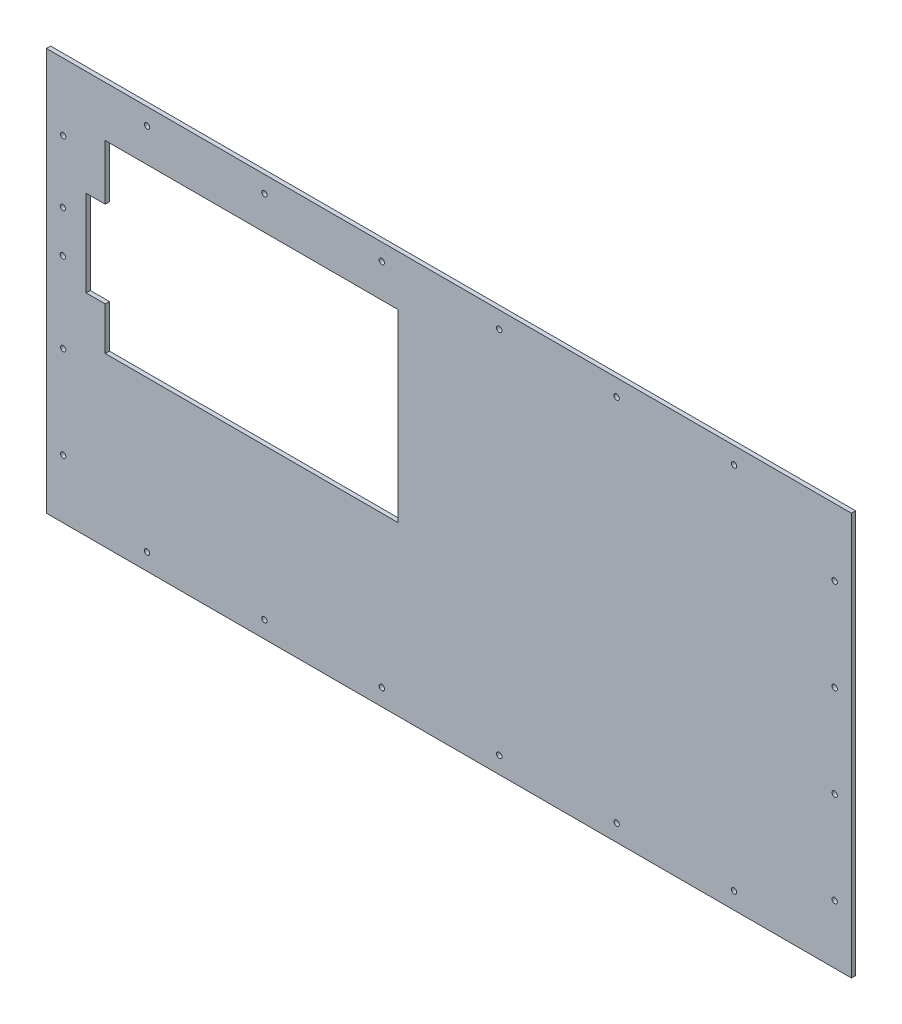
from build123d import *

# Parameters (mm, degrees)
SKETCH1_W               = 609.6
SKETCH1_H               = 304.8
BOSS_EXTRUDE1_DEPTH     = 3.175
SKETCH5_R               = 2.032
CUT_EXTRUDE4_DEPTH      = 4.175
SKETCH6_R               = 2.032
CUT_EXTRUDE5_DEPTH      = 10
CUT_EXTRUDE5_DEPTH_BACK = 3.175
SKETCH20_R              = 2.032
CUT_EXTRUDE17_DEPTH     = 4.175
SKETCH8_W               = 221.700000084
SKETCH8_H               = 139.7
CUT_EXTRUDE6_DEPTH      = 3.175
SKETCH19_W              = 14.489703264
SKETCH19_H              = 65.374013416
CUT_EXTRUDE16_DEPTH     = 4.175


with BuildPart() as part:
    # Sketch1 → Boss-Extrude1 (new body)
    with BuildSketch(Plane.XY):
        with Locations((-304.8, 152.4)):
            Rectangle(SKETCH1_W, SKETCH1_H)
    extrude(amount=BOSS_EXTRUDE1_DEPTH)

    # Sketch5 → Cut-Extrude4 (cut, through all)
    with BuildSketch(Plane.XY.offset(3.175)):
        with Locations((-533.4, 12.7)):
            Circle(SKETCH5_R)
        with Locations((-444.5, 12.7)):
            Circle(SKETCH5_R)
        with Locations((-355.6, 12.7)):
            Circle(SKETCH5_R)
        with Locations((-266.7, 12.7)):
            Circle(SKETCH5_R)
        with Locations((-177.8, 12.7)):
            Circle(SKETCH5_R)
        with Locations((-88.9, 12.7)):
            Circle(SKETCH5_R)
        with Locations((-88.9, 292.1)):
            Circle(SKETCH5_R)
        with Locations((-177.8, 292.1)):
            Circle(SKETCH5_R)
        with Locations((-266.7, 292.1)):
            Circle(SKETCH5_R)
        with Locations((-355.6, 292.1)):
            Circle(SKETCH5_R)
        with Locations((-444.5, 292.1)):
            Circle(SKETCH5_R)
        with Locations((-533.4, 292.1)):
            Circle(SKETCH5_R)
    extrude(amount=-CUT_EXTRUDE4_DEPTH, mode=Mode.SUBTRACT)

    # Sketch6 → Cut-Extrude5 (cut, two sides)
    with BuildSketch(Plane.XY.offset(3.175)) as cut_extrude5_sk:
        with Locations((-596.9, 254)):
            Circle(SKETCH6_R)
        with Locations((-596.9, 114.3)):
            Circle(SKETCH6_R)
        with Locations((-596.9, 44.45)):
            Circle(SKETCH6_R)
        with Locations((-12.7, 254)):
            Circle(SKETCH6_R)
        with Locations((-12.7, 184.15)):
            Circle(SKETCH6_R)
        with Locations((-12.7, 114.3)):
            Circle(SKETCH6_R)
        with Locations((-12.7, 44.45)):
            Circle(SKETCH6_R)
    extrude(amount=CUT_EXTRUDE5_DEPTH, mode=Mode.SUBTRACT)
    extrude(cut_extrude5_sk.sketch, amount=-CUT_EXTRUDE5_DEPTH_BACK, mode=Mode.SUBTRACT)

    # Sketch20 → Cut-Extrude17 (cut, through all)
    with BuildSketch(Plane.XY.offset(3.175)):
        with Locations((-597.110646497, 175.018670592)):
            Circle(SKETCH20_R)
        with Locations((-597.110646497, 206.768670592)):
            Circle(SKETCH20_R)
    extrude(amount=-CUT_EXTRUDE17_DEPTH, mode=Mode.SUBTRACT)

    # Sketch8 → Cut-Extrude6 (cut)
    with BuildSketch(Plane.XY.offset(3.175)):
        with Locations((-454.183579328, 196.85)):
            Rectangle(SKETCH8_W, SKETCH8_H)
    extrude(amount=-CUT_EXTRUDE6_DEPTH, mode=Mode.SUBTRACT)

    # Sketch19 → Cut-Extrude16 (cut, through all)
    with BuildSketch(Plane(origin=(0, 0, 0), x_dir=(-1, 0, 0), z_dir=(0, 0, -1))):
        with Locations((572.278431002, 192.206332301)):
            Rectangle(SKETCH19_W, SKETCH19_H)
    extrude(amount=-CUT_EXTRUDE16_DEPTH, mode=Mode.SUBTRACT)


solid = part.part
